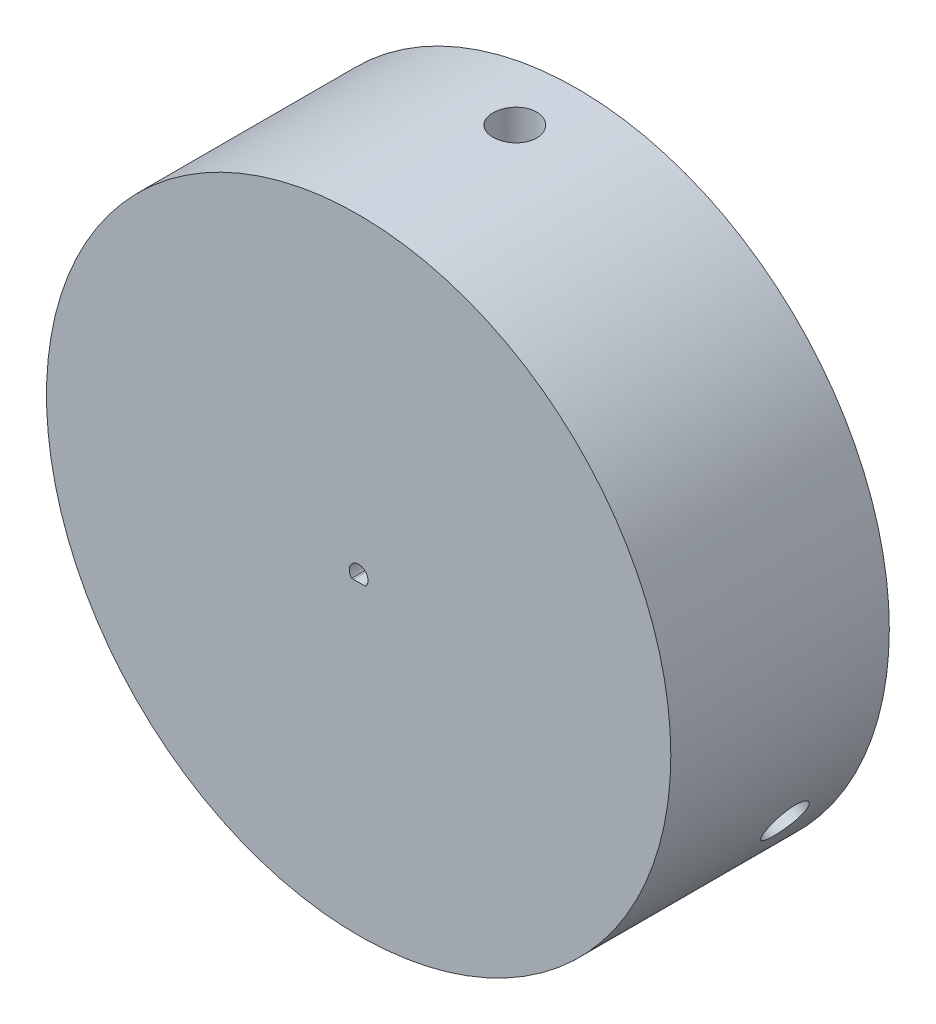
from build123d import *

# Parameters (mm, degrees)
SKETCH2_R           = 50
BOSS_EXTRUDE1_DEPTH = 35
SKETCH3_W           = 8
SKETCH3_H           = 35
CUT_EXTRUDE1_DEPTH  = 20
SKETCH4_R           = 3.5
CUT_EXTRUDE2_DEPTH  = 80
SKETCH5_R           = 3.5
CUT_EXTRUDE3_DEPTH  = 50
SKETCH6_R           = 3.5
CUT_EXTRUDE4_DEPTH  = 50
SKETCH8_W           = 14.038446545
SKETCH8_H           = 6.5
CUT_EXTRUDE5_DEPTH  = 15.5
SKETCH11_W          = 8
SKETCH11_H          = 6.5
BOSS_EXTRUDE2_DEPTH = 4.5
BOSS_EXTRUDE3_DEPTH = 15.5
BOSS_EXTRUDE4_DEPTH = 35
SKETCH18_R          = 3.5
CUT_EXTRUDE9_DEPTH  = 25
SKETCH19_R          = 3.5
CUT_EXTRUDE10_DEPTH = 25
SKETCH20_R          = 3.5
CUT_EXTRUDE11_DEPTH = 25
SKETCH21_W          = 5.1
SKETCH21_H          = 18.4
CUT_EXTRUDE12_DEPTH = 13
SKETCH23_W          = 5.1
SKETCH23_H          = 18.4
CUT_EXTRUDE13_DEPTH = 13
SKETCH22_W          = 5.1
SKETCH22_H          = 13.3
BOSS_EXTRUDE5_DEPTH = 7.9
CUT_EXTRUDE14_DEPTH = 8.5
SKETCH25_R          = 9
CUT_EXTRUDE15_DEPTH = 20


with BuildPart() as part:
    # Sketch2 → Boss-Extrude1 (new body)
    with BuildSketch(Plane.XY):
        Circle(SKETCH2_R)
    extrude(amount=BOSS_EXTRUDE1_DEPTH)

    # Sketch3 → Cut-Extrude1 (cut)
    with BuildSketch(Plane(origin=(0, 0, 0), x_dir=(-1, 0, 0), z_dir=(0, 0, -1))):
        with Locations((0, 21.5)):
            Rectangle(SKETCH3_W, SKETCH3_H)
        Polygon((31.774990748, -22.964101615), (35.774990748, -16.035898385), (5.464101615, 1.464101615), (1.464101615, -5.464101615), align=None)
        Polygon((-35.774990748, -16.035898385), (-31.774990748, -22.964101615), (-1.464101615, -5.464101615), (-5.464101615, 1.464101615), align=None)
    extrude(amount=-CUT_EXTRUDE1_DEPTH, mode=Mode.SUBTRACT)

    # Sketch4 → Cut-Extrude2 (cut)
    with BuildSketch(Plane(origin=(-3.464101615, -2, 0), x_dir=(0, 0, 1), z_dir=(-0.866025404, -0.5, 0))):
        with Locations((10, 0)):
            Circle(SKETCH4_R)
    extrude(amount=CUT_EXTRUDE2_DEPTH, mode=Mode.SUBTRACT)

    # Sketch5 → Cut-Extrude3 (cut)
    with BuildSketch(Plane(origin=(0, 4, 0), x_dir=(1, 0, 0), z_dir=(0, 1, 0))):
        with Locations((0, -10)):
            Circle(SKETCH5_R)
    extrude(amount=CUT_EXTRUDE3_DEPTH, mode=Mode.SUBTRACT)

    # Sketch6 → Cut-Extrude4 (cut)
    with BuildSketch(Plane(origin=(3.464101615, -2, 0), x_dir=(0, 0, -1), z_dir=(0.866025404, -0.5, 0))):
        with Locations((-10, 0)):
            Circle(SKETCH6_R)
    extrude(amount=CUT_EXTRUDE4_DEPTH, mode=Mode.SUBTRACT)

    # Sketch8 → Cut-Extrude5 (cut)
    with BuildSketch(Plane(origin=(0, 0, 0), x_dir=(-1, 0, 0), z_dir=(0, 0, -1))):
        Polygon((-32.971083956, -10.892407408), (-25.951860683, -23.050058746), (-20.322695558, -19.800058746), (-27.341918831, -7.642407408), align=None)
        with Locations((0.033217181, 30.75)):
            Rectangle(SKETCH8_W, SKETCH8_H)
        Polygon((27.30870165, -7.699941254), (32.937866774, -10.949941254), (25.918643502, -23.107592592), (20.289478377, -19.857592592), align=None)
    extrude(amount=-CUT_EXTRUDE5_DEPTH, mode=Mode.SUBTRACT)

    # Sketch11 → Boss-Extrude2 (add)
    with BuildSketch(Plane(origin=(0, 0, 20), x_dir=(-1, 0, 0), z_dir=(0, 0, -1))):
        with Locations((0, 30.75)):
            Rectangle(SKETCH11_W, SKETCH11_H)
        Polygon((25.815698604, -10.285898385), (31.444863729, -13.535898385), (27.444863729, -20.464101615), (21.815698604, -17.214101615), align=None)
        Polygon((-21.815698604, -17.214101615), (-27.444863729, -20.464101615), (-31.444863729, -13.535898385), (-25.815698604, -10.285898385), align=None)
    extrude(amount=BOSS_EXTRUDE2_DEPTH)

    # Sketch12 → Boss-Extrude3 (add)
    with BuildSketch(Plane(origin=(0, 0, 15.5), x_dir=(-1, 0, 0), z_dir=(0, 0, -1))):
        Polygon((-6.986006091, 32.1), (7.052440454, 32.1), (7.052440454, 34), (4, 34), (4, 39), (-4, 39), (-4, 34), (-6.986006091, 34), align=None)
        Polygon((25.918643502, -23.107592592), (27.444863729, -20.464101615), (31.774990748, -22.964101615), (35.774990748, -16.035898385), (31.444863729, -13.535898385), (32.937866774, -10.949941254), (31.292418507, -9.999941254), (24.273195235, -22.157592592), align=None)
        Polygon((-32.971083956, -10.892407408), (-31.444863729, -13.535898385), (-35.774990748, -16.035898385), (-31.774990748, -22.964101615), (-27.444863729, -20.464101615), (-25.951860683, -23.050058746), (-24.306412416, -22.100058746), (-31.325635688, -9.942407408), align=None)
    extrude(amount=BOSS_EXTRUDE3_DEPTH)

    # Sketch17 → Boss-Extrude4 (add)
    with BuildSketch(Plane(origin=(0, 0, 0), x_dir=(-1, 0, 0), z_dir=(0, 0, -1))):
        Polygon((-5.842787082, 32.897450406), (-5.842787082, 43.509531182), (5.727819383, 43.509531182), (5.754751517, 32.897450406), align=None)
        Polygon((31.411421312, -11.388723161), (25.612652013, -21.432486209), (34.816449619, -26.715202685), (40.601752851, -16.69476355), align=None)
        Polygon((-25.568634231, -21.508727245), (-31.36740353, -11.464964197), (-40.544269002, -16.794328497), (-34.75896577, -26.814767633), align=None)
    extrude(amount=-BOSS_EXTRUDE4_DEPTH)

    # Sketch18 → Cut-Extrude9 (cut, symmetric)
    with BuildSketch(Plane(origin=(-37.680359311, -21.754765591, 0), x_dir=(0, 0, 1), z_dir=(-0.866025404, -0.5, 0))):
        with Locations((10, 0)):
            Circle(SKETCH18_R)
    extrude(amount=CUT_EXTRUDE9_DEPTH, both=True, mode=Mode.SUBTRACT)

    # Sketch19 → Cut-Extrude10 (cut, symmetric)
    with BuildSketch(Plane(origin=(37.680359311, -21.754765591, 0), x_dir=(0, 0, -1), z_dir=(0.866025404, -0.5, 0))):
        with Locations((-10, 0)):
            Circle(SKETCH19_R)
    extrude(amount=CUT_EXTRUDE10_DEPTH, both=True, mode=Mode.SUBTRACT)

    # Sketch20 → Cut-Extrude11 (cut, symmetric)
    with BuildSketch(Plane(origin=(0, 43.509531182, 0), x_dir=(1, 0, 0), z_dir=(0, 1, 0))):
        with Locations((0, -10)):
            Circle(SKETCH20_R)
    extrude(amount=CUT_EXTRUDE11_DEPTH, both=True, mode=Mode.SUBTRACT)

    # Sketch21 → Cut-Extrude12 (cut)
    with BuildSketch(Plane(origin=(0, 0, 0), x_dir=(-1, 0, 0), z_dir=(0, 0, -1))):
        with Locations((6.55, 13.2)):
            Rectangle(SKETCH21_W, SKETCH21_H)
    extrude(amount=-CUT_EXTRUDE12_DEPTH, mode=Mode.SUBTRACT)

    # Sketch23 → Cut-Extrude13 (cut)
    with BuildSketch(Plane(origin=(0, 0, 0), x_dir=(-1, 0, 0), z_dir=(0, 0, -1))):
        with Locations((6.55, 13.2)):
            Rectangle(SKETCH23_W, SKETCH23_H)
        Polygon((-1.085898385, -9.880831174), (1.464101615, -5.464101615), (17.398969045, -14.664101615), (14.848969045, -19.080831174), align=None)
        Polygon((-8.014101615, 5.880831174), (-5.464101615, 1.464101615), (-21.398969045, -7.735898385), (-23.948969045, -3.319168826), align=None)
    extrude(amount=-CUT_EXTRUDE13_DEPTH, mode=Mode.SUBTRACT)

    # Sketch22 → Boss-Extrude5 (add)
    with BuildSketch(Plane(origin=(0, 0, 0), x_dir=(-1, 0, 0), z_dir=(0, 0, -1))):
        with Locations((6.55, 10.65)):
            Rectangle(SKETCH22_W, SKETCH22_H)
        Polygon((-1.085898385, -9.880831174), (1.464101615, -5.464101615), (12.982239485, -12.114101615), (10.432239485, -16.530831174), align=None)
        Polygon((-8.014101615, 5.880831174), (-5.464101615, 1.464101615), (-16.982239485, -5.185898385), (-19.532239485, -0.769168826), align=None)
    extrude(amount=-BOSS_EXTRUDE5_DEPTH)

    # Sketch24 → Cut-Extrude14 (cut)
    with BuildSketch(Plane.XY.offset(35)):
        with BuildLine():
            Line((0.831568399, -1), (1.11810064, -0.999925477))
            ThreePointArc((1.11810064, -0.999925477), (0.535186435, 1.401276375), (-1.5, 0))
            ThreePointArc((-1.5, 0), (-1.401274891, -0.535190321), (-1.118095094, -0.999931678))
            Line((-1.118095094, -0.999931678), (-0.831313787, -1))
            Line((-0.831313787, -1), (0.831568399, -1))
        make_face()
    extrude(amount=-CUT_EXTRUDE14_DEPTH, mode=Mode.SUBTRACT)

    # Sketch25 → Cut-Extrude15 (cut)
    with BuildSketch(Plane(origin=(0, 0, 0), x_dir=(-1, 0, 0), z_dir=(0, 0, -1))):
        Circle(SKETCH25_R)
    extrude(amount=-CUT_EXTRUDE15_DEPTH, mode=Mode.SUBTRACT)


solid = part.part
